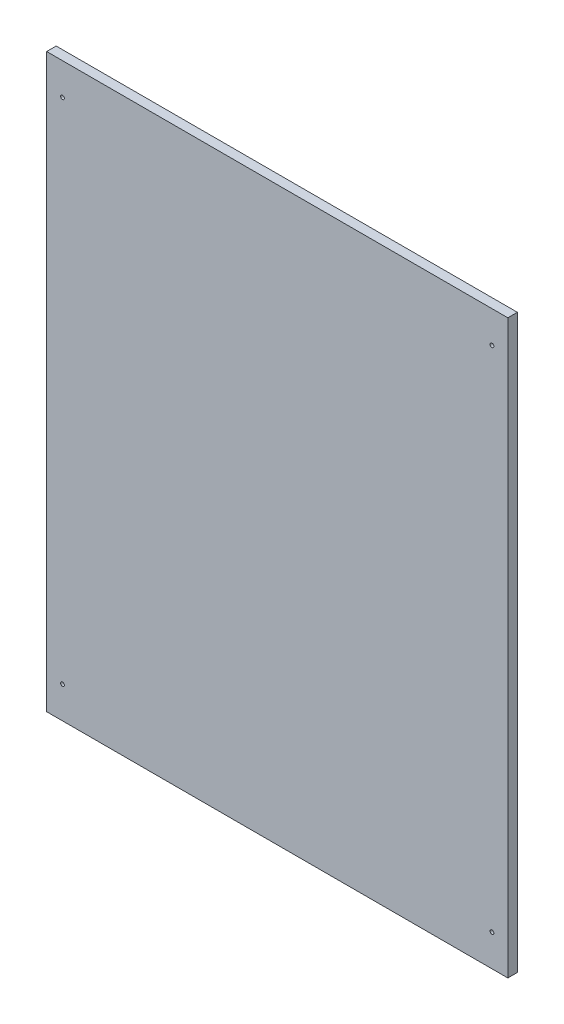
from build123d import *

# Parameters (mm, degrees)
SKETCH_1_R      = 3
EXTRUDE_1_DEPTH = 15


with BuildPart() as part:
    # 草图1 → 凸台-拉伸1 (new body)
    with BuildSketch(Plane.XY):
        Polygon((-10, -835), (-10, -15), (-10, 25), (716, 25), (716, -15), (716, -835), (716, -875), (-10, -875), align=None)
        with Locations((15, -25)):
            Circle(SKETCH_1_R, mode=Mode.SUBTRACT)
        with Locations((691, -25)):
            Circle(SKETCH_1_R, mode=Mode.SUBTRACT)
        with Locations((691, -825)):
            Circle(SKETCH_1_R, mode=Mode.SUBTRACT)
        with Locations((15, -825)):
            Circle(SKETCH_1_R, mode=Mode.SUBTRACT)
    extrude(amount=EXTRUDE_1_DEPTH)


solid = part.part
